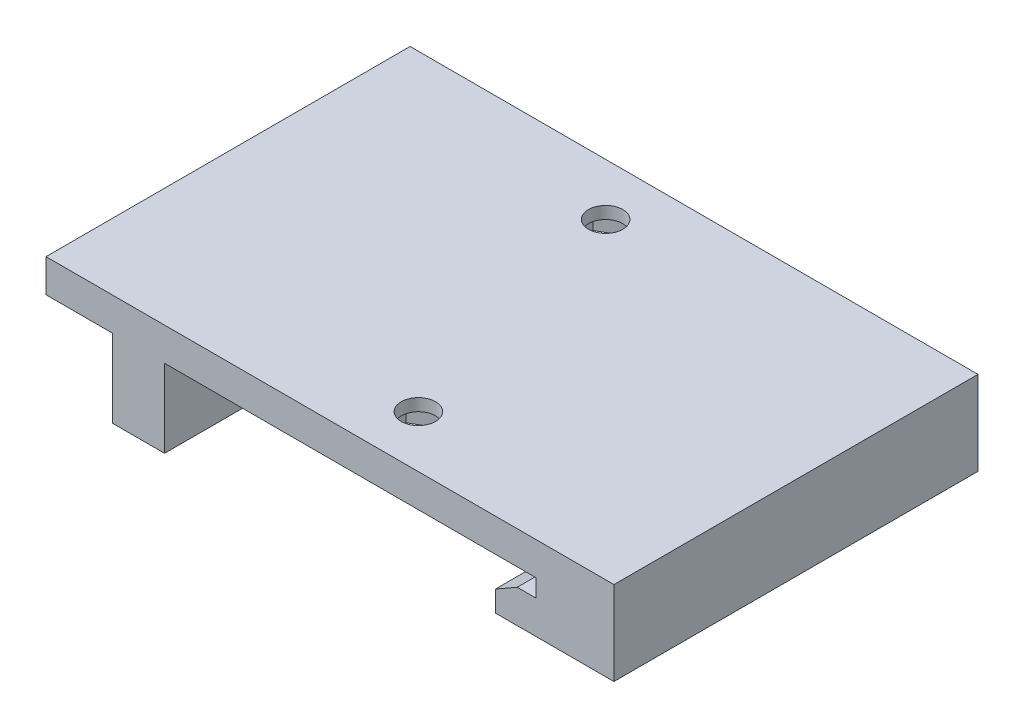
from build123d import *

# Parameters (mm, degrees)
BOSS_EXTRUDE1_DEPTH = 35
SKETCH2_R           = 1.275
CUT_EXTRUDE1_DEPTH  = 5
SKETCH5_R           = 1.65
CUT_EXTRUDE2_DEPTH  = 2
SKETCH6_R           = 1.65
CUT_EXTRUDE3_DEPTH  = 4.175


with BuildPart() as part:
    # Sketch1 → Boss-Extrude1 (new body)
    with BuildSketch(Plane.XY):
        Polygon((0, 0), (19.8, 0), (19.8, -1.7), (18, -1.7), (15.9, -2.9), (15.9, -4.9), (27.3, -4.9), (27.3, 3.175), (-27.3, 3.175), (-27.3, 0), (-20.9, 0), (-20.9, -7.5), (-15.9, -7.5), (-15.9, 0), align=None)
    extrude(amount=BOSS_EXTRUDE1_DEPTH)

    # Sketch2 → Cut-Extrude1 (cut)
    with BuildSketch(Plane.ZY.offset(20.9)):
        with Locations((8.75, -3.75)):
            Circle(SKETCH2_R)
        with Locations((26.25, -3.75)):
            Circle(SKETCH2_R)
    extrude(amount=-CUT_EXTRUDE1_DEPTH, mode=Mode.SUBTRACT)

    # Sketch5 → Cut-Extrude2 (cut)
    with BuildSketch(Plane.XZ):
        Polygon((6.35, 28.354551733), (6.35, 31.645448267), (3.5, 33.290896534), (0.65, 31.645448267), (0.65, 28.354551733), (3.5, 26.709103466), align=None)
        with Locations((3.5, 30)):
            Circle(SKETCH5_R, mode=Mode.SUBTRACT)
        Polygon((-0.65, 6.645448267), (-3.5, 8.290896534), (-6.35, 6.645448267), (-6.35, 3.354551733), (-3.5, 1.709103466), (-0.65, 3.354551733), align=None)
        with Locations((-3.5, 5)):
            Circle(SKETCH5_R, mode=Mode.SUBTRACT)
    extrude(amount=-CUT_EXTRUDE2_DEPTH, mode=Mode.SUBTRACT)

    # Sketch6 → Cut-Extrude3 (cut, through all)
    with BuildSketch(Plane.XZ):
        with Locations((3.5, 30)):
            Circle(SKETCH6_R)
        with Locations((-3.5, 5)):
            Circle(SKETCH6_R)
    extrude(amount=-CUT_EXTRUDE3_DEPTH, mode=Mode.SUBTRACT)


solid = part.part
